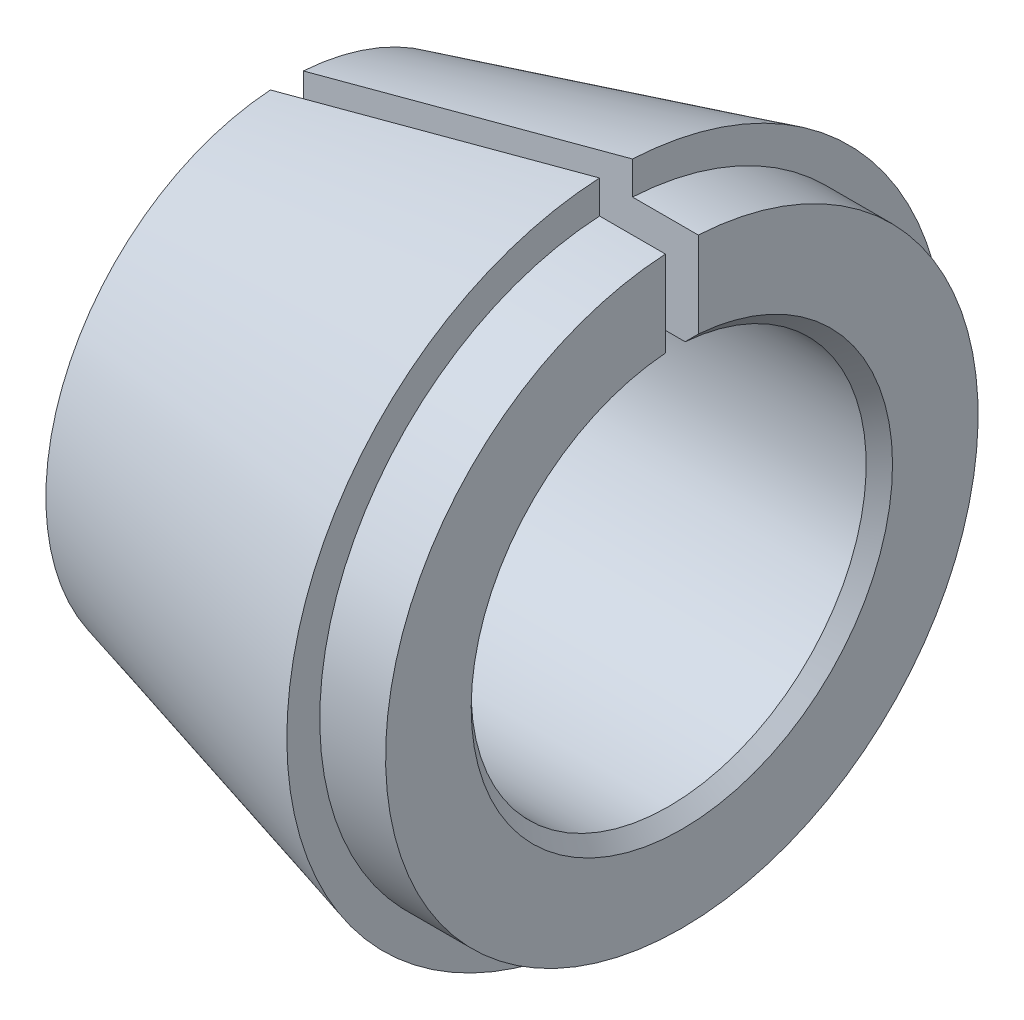
from build123d import *

# Parameters (mm, degrees)
SKETCH2_W          = 6
SKETCH2_H          = 0.5
CUT_EXTRUDE1_DEPTH = 6


with BuildPart() as part:
    # Sketch1 → Revolve1 (revolve)
    with BuildSketch(Plane.XY):
        Polygon((-5.8, 3), (-0.2, 3), (0, 3.2), (0, 4.5), (-1, 4.5), (-1, 5), (-6, 3.660254038), (-6, 3.2), align=None)
    revolve(axis=Axis((0, 0, 0), (-1, 0, 0)))

    # Sketch2 → Cut-Extrude1 (cut, through all)
    with BuildSketch(Plane(origin=(0, 0, 0), x_dir=(1, 0, 0), z_dir=(0, 1, 0))):
        with Locations((-3, 0)):
            Rectangle(SKETCH2_W, SKETCH2_H)
    extrude(amount=CUT_EXTRUDE1_DEPTH, mode=Mode.SUBTRACT)


solid = part.part
